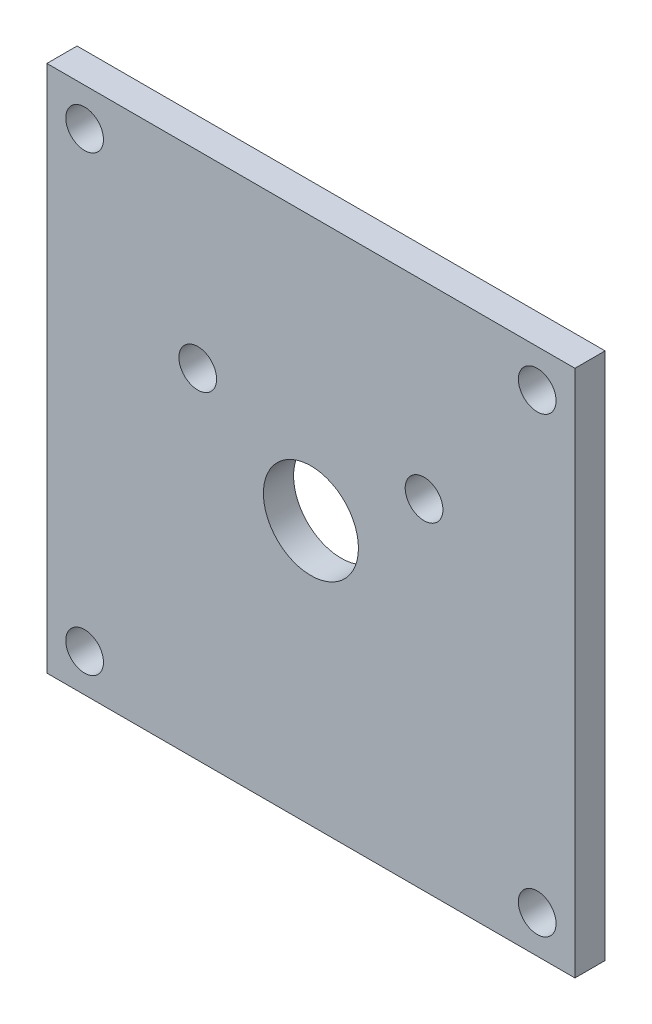
from build123d import *

# Parameters (mm, degrees)
SKETCH1_W           = 88.9
SKETCH1_H           = 88.9
BOSS_EXTRUDE1_DEPTH = 2.54
SKETCH2_R           = 3.175
SKETCH2_R_2         = 8.001
CUT_EXTRUDE1_DEPTH  = 6.08


with BuildPart() as part:
    # Sketch1 → Boss-Extrude1 (new body, symmetric)
    with BuildSketch(Plane.XY):
        with Locations((44.45, 44.45)):
            Rectangle(SKETCH1_W, SKETCH1_H)
    extrude(amount=BOSS_EXTRUDE1_DEPTH, both=True)

    # Sketch2 → Cut-Extrude1 (cut, through all)
    with BuildSketch(Plane.XY.offset(2.54)):
        with Locations((6.35, 82.55)):
            Circle(SKETCH2_R)
        with Locations((82.55, 82.55)):
            Circle(SKETCH2_R)
        with Locations((82.55, 6.35)):
            Circle(SKETCH2_R)
        with Locations((6.35, 6.35)):
            Circle(SKETCH2_R)
        with Locations((44.45, 44.45)):
            Circle(SKETCH2_R_2)
        with Locations((25.4, 57.15)):
            Circle(SKETCH2_R)
        with Locations((63.5, 57.15)):
            Circle(SKETCH2_R)
    extrude(amount=-CUT_EXTRUDE1_DEPTH, mode=Mode.SUBTRACT)


solid = part.part
